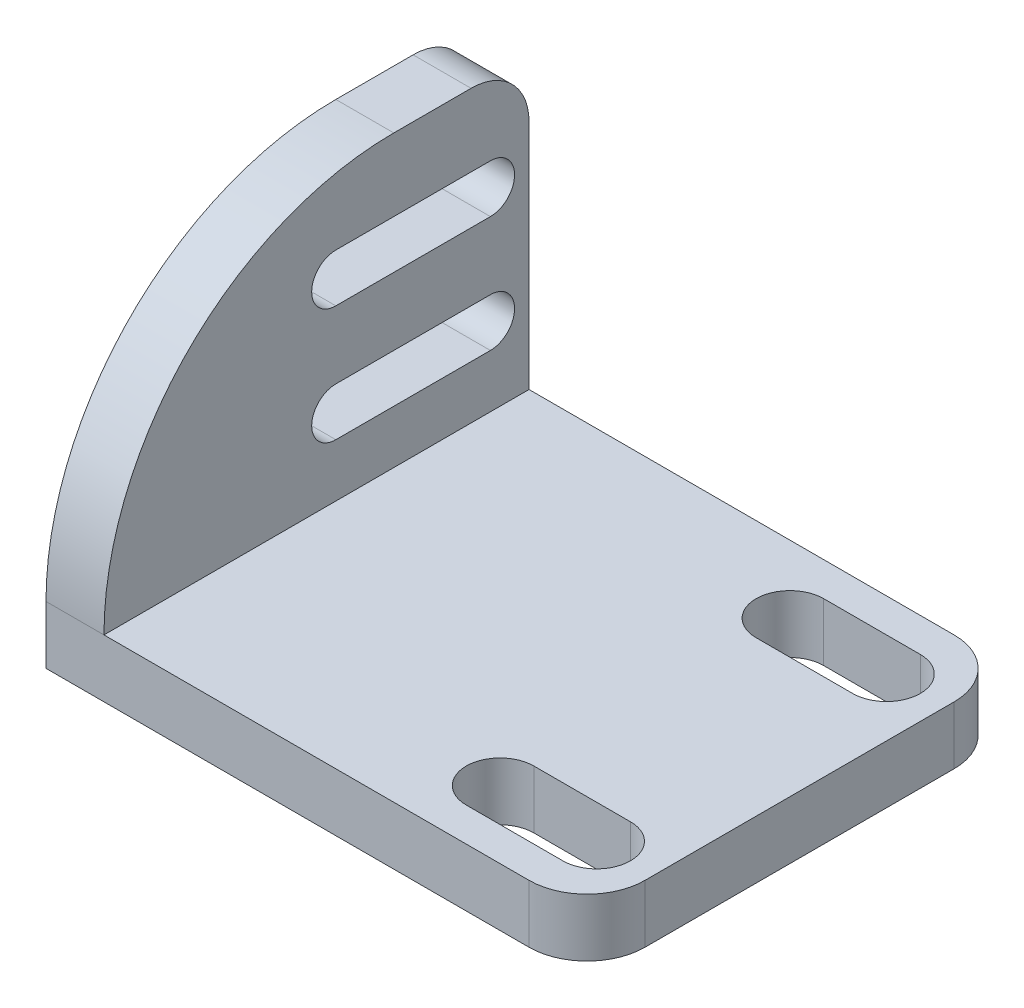
from build123d import *

# Parameters (mm, degrees)
BOSS_EXTRUDE1_DEPTH = 22
CUT_EXTRUDE1_DEPTH  = 4
CUT_EXTRUDE2_DEPTH  = 4
FILLET1_R           = 15
FILLET2_R           = 3


with BuildPart() as part:
    # Sketch1 → Boss-Extrude1 (new body)
    with BuildSketch(Plane.XY):
        Polygon((0, 0), (0, 15), (-3, 15), (-3, -3), (25, -3), (25, 0), align=None)
    extrude(amount=BOSS_EXTRUDE1_DEPTH)

    # Sketch2 → Cut-Extrude1 (cut, through all)
    with BuildSketch(Plane(origin=(0, 0, 0), x_dir=(1, 0, 0), z_dir=(0, 1, 0))):
        with BuildLine():
            Line((17, -1.75), (22, -1.75))
            ThreePointArc((22, -1.75), (23.75, -3.5), (22, -5.25))
            Line((22, -5.25), (17, -5.25))
            ThreePointArc((17, -5.25), (15.25, -3.5), (17, -1.75))
        make_face()
        with BuildLine():
            Line((17, -16.75), (22, -16.75))
            ThreePointArc((22, -16.75), (23.75, -18.5), (22, -20.25))
            Line((22, -20.25), (17, -20.25))
            ThreePointArc((17, -20.25), (15.25, -18.5), (17, -16.75))
        make_face()
    extrude(amount=-CUT_EXTRUDE1_DEPTH, mode=Mode.SUBTRACT)

    # Sketch3 → Cut-Extrude2 (cut, through all)
    with BuildSketch(Plane(origin=(0, 0, 0), x_dir=(0, 0, -1), z_dir=(1, 0, 0))):
        with BuildLine():
            Line((-10, 11.25), (-2, 11.25))
            ThreePointArc((-2, 11.25), (-0.75, 10), (-2, 8.75))
            Line((-2, 8.75), (-10, 8.75))
            ThreePointArc((-10, 8.75), (-11.25, 10), (-10, 11.25))
        make_face()
        with BuildLine():
            Line((-10, 5.25), (-2, 5.25))
            ThreePointArc((-2, 5.25), (-0.75, 4), (-2, 2.75))
            Line((-2, 2.75), (-10, 2.75))
            ThreePointArc((-10, 2.75), (-11.25, 4), (-10, 5.25))
        make_face()
    extrude(amount=-CUT_EXTRUDE2_DEPTH, mode=Mode.SUBTRACT)

    # Fillet1
    fillet1_edges = [part.edges().sort_by_distance(p)[0] for p in [
        (-1.5, 15, 22),
    ]]
    fillet(fillet1_edges, radius=FILLET1_R)

    # Fillet2
    fillet2_edges = [part.edges().sort_by_distance(p)[0] for p in [
        (25, -1.5, 22),
        (25, -1.5, 0),
        (-1.5, 15, 0),
    ]]
    fillet(fillet2_edges, radius=FILLET2_R)


solid = part.part
